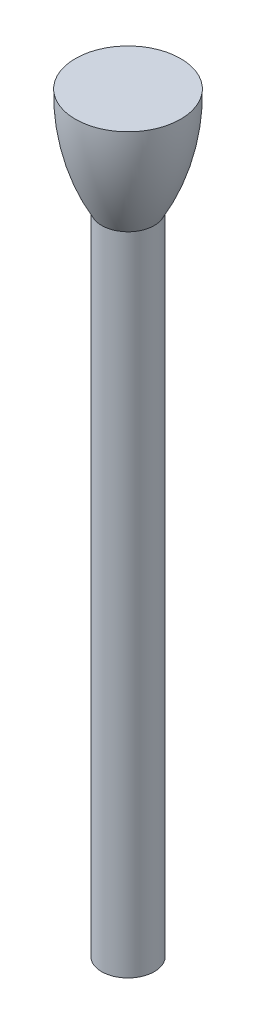
from build123d import *

# Parameters (mm, degrees)
SKETCH1_R           = 11.1125
BOSS_EXTRUDE1_DEPTH = 136.525


with BuildPart() as part:
    # Sketch1 → Boss-Extrude1 (new body, symmetric)
    with BuildSketch(Plane(origin=(0, 0, 0), x_dir=(1, 0, 0), z_dir=(0, 1, 0))):
        Circle(SKETCH1_R)
    extrude(amount=BOSS_EXTRUDE1_DEPTH, both=True)

    # Sketch3 → Revolve1 (revolve)
    with BuildSketch(Plane.XY):
        with BuildLine():
            Line((0, 136.525), (0, 180.975))
            Line((0, 180.975), (-22.225, 180.975))
            ThreePointArc((-22.225, 180.975), (-19.609004826, 158.014936294), (-11.1125, 136.525))
            Line((-11.1125, 136.525), (0, 136.525))
        make_face()
    revolve(axis=Axis((0, 136.525, 0), (0, 1, 0)))


solid = part.part
